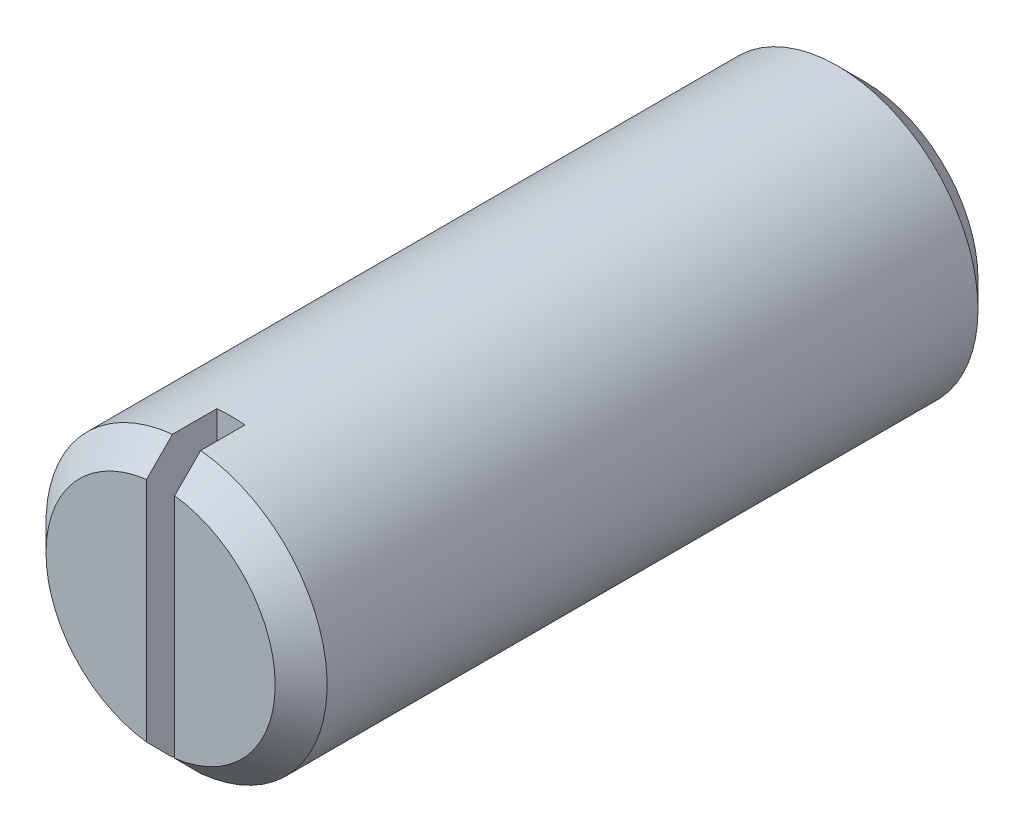
from build123d import *

# Parameters (mm, degrees)
SKETCH_1_R          = 3
EXTRUDE_1_DEPTH     = 15
CHAMFER_1_SIZE      = 0.5545
SKETCH_2_W          = 0.6
SKETCH_2_H          = 7
CUT_EXTRUDE_1_DEPTH = 1.5


with BuildPart() as part:
    # Эскиз1 → Бобышка-Вытянуть1 (new body)
    with BuildSketch(Plane.XY):
        Circle(SKETCH_1_R)
    extrude(amount=EXTRUDE_1_DEPTH)

    # Фаска1
    chamfer_1_edges = [part.edges().sort_by_distance(p)[0] for p in [
        (-3, 0, 0),
        (-3, 0, 15),
    ]]
    chamfer(chamfer_1_edges, length=CHAMFER_1_SIZE)

    # Эскиз2 → Вырез-Вытянуть1 (cut)
    with BuildSketch(Plane.XY.offset(15)):
        Rectangle(SKETCH_2_W, SKETCH_2_H)
    extrude(amount=-CUT_EXTRUDE_1_DEPTH, mode=Mode.SUBTRACT)


solid = part.part
